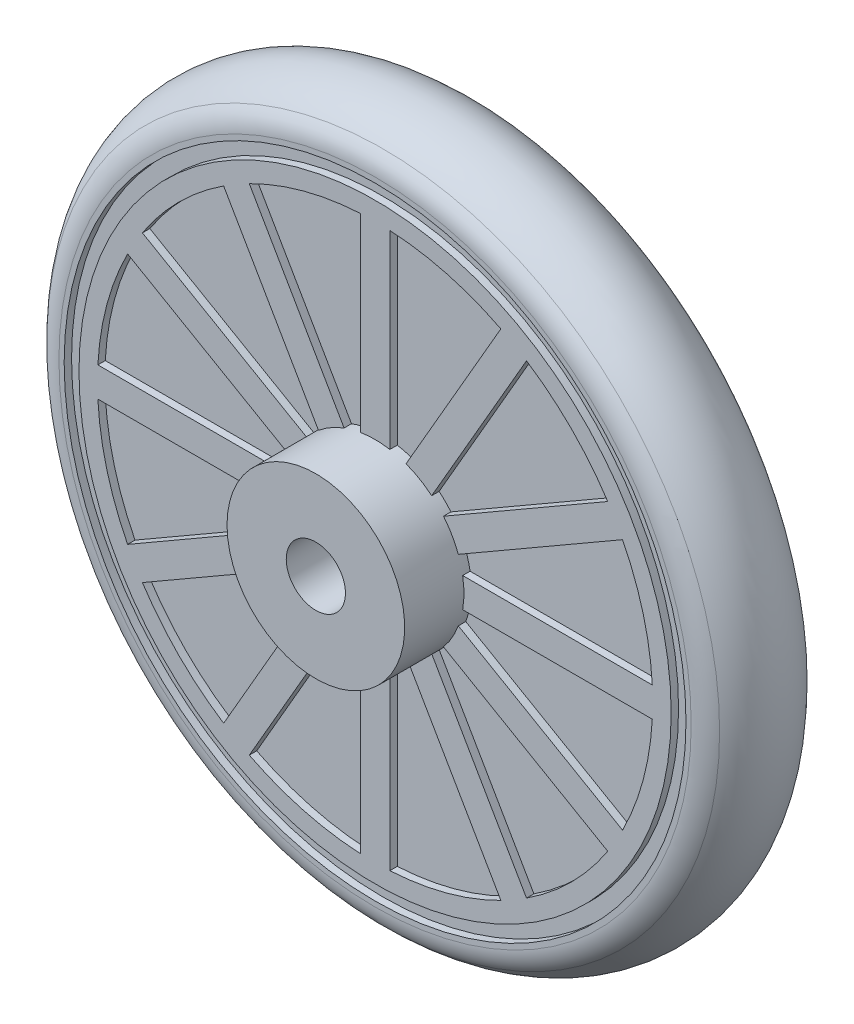
from build123d import *

# Parameters (mm, degrees)
SKETCH2_R          = 21
SKETCH2_R_2        = 20
CUT_EXTRUDE1_DEPTH = 0.5
FILLET1_R          = 2
CUT_EXTRUDE2_DEPTH = 0.5
CIRPATTERN1_COUNT  = 12


with BuildPart() as part:
    # Sketch1 → Revolve1 (revolve)
    with BuildSketch(Plane(origin=(0, 0, 0), x_dir=(1, 0, 0), z_dir=(0, 1, 0))):
        with BuildLine():
            Line((2, 0), (2, 7.5))
            Line((2, 7.5), (6, 7.5))
            Line((6, 7.5), (6, 3.5))
            Line((6, 3.5), (22, 3.5))
            ThreePointArc((22, 3.5), (23.464737765, 2.015564437), (24, 0))
            Line((24, 0), (2, 0))
        make_face()
    revolve(axis=Axis((0, 0, -79.664313946), (0, 0, 1)))

    # Sketch2 → Cut-Extrude1 (cut)
    with BuildSketch(Plane(origin=(0, 0, -3.5), x_dir=(-1, 0, 0), z_dir=(0, 0, -1))):
        Circle(SKETCH2_R)
        Circle(SKETCH2_R_2, mode=Mode.SUBTRACT)
    extrude(amount=-CUT_EXTRUDE1_DEPTH, mode=Mode.SUBTRACT)

    # Fillet1
    fillet1_edges = [part.edges().sort_by_distance(p)[0] for p in [
        (-22, 0, -3.5),
    ]]
    fillet(fillet1_edges, radius=FILLET1_R)

    # Sketch3 → Cut-Extrude2 (cut)
    with BuildSketch(Plane(origin=(0, 0, -3.5), x_dir=(-1, 0, 0), z_dir=(0, 0, -1))):
        with BuildLine():
            Line((1, 18.723314343), (1, 5.916079783))
            ThreePointArc((1, 5.916079783), (1.552914271, 5.795554958), (2.092014488, 5.623475383))
            Line((2.092014488, 5.623475383), (8.495631768, 16.714865864))
            ThreePointArc((8.495631768, 16.714865864), (4.852857096, 18.111109243), (1, 18.723314343))
        make_face()
    cut_extrude2 = extrude(amount=-CUT_EXTRUDE2_DEPTH, mode=Mode.SUBTRACT)

    # CirPattern1: Cut-Extrude2 ×12 about axis
    cirpattern1_axis = Axis((0, 0, 0), (0, 0, 1))
    for i in range(1, CIRPATTERN1_COUNT):
        add(cut_extrude2.rotate(cirpattern1_axis, i * 360 / CIRPATTERN1_COUNT), mode=Mode.SUBTRACT)

    # Mirror1: part across plane


with BuildPart() as part_1:
    add(part.part)
    add(part.part.mirror(Plane(origin=(2, 0, 0), x_dir=(1, 0, 0), z_dir=(0, 0, -1))))


solid = part_1.part
